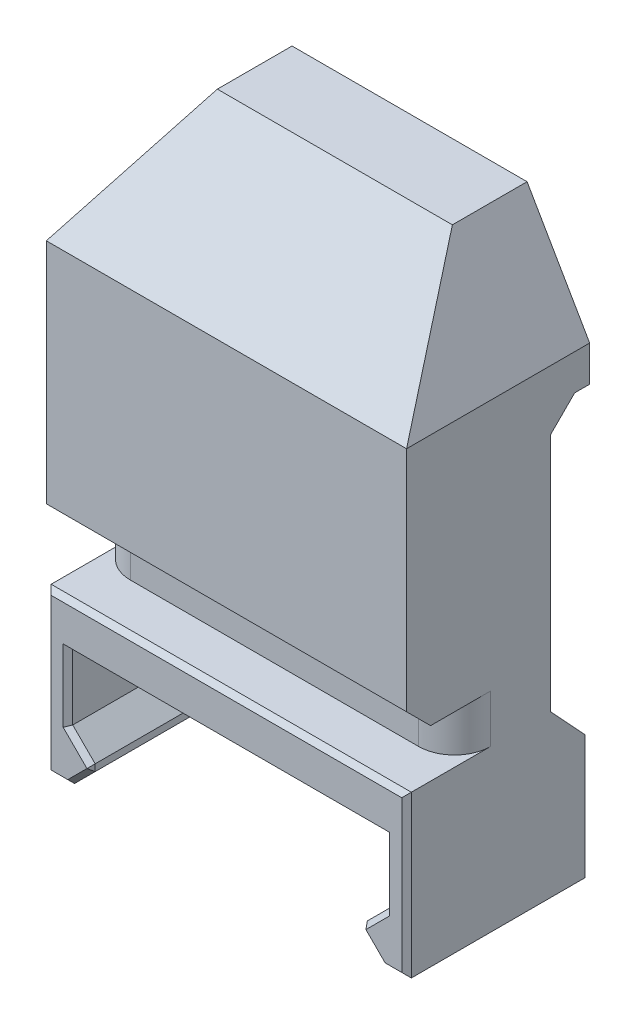
from build123d import *

# Parameters (mm, degrees)
BOSS_EXTRUDE1_DEPTH = 15
FILLET1_R           = 3
CUT_EXTRUDE1_DEPTH  = 16.25
CHAMFER1_SIZE       = 0.4
CUT_EXTRUDE2_DEPTH  = 16.25
CHAMFER2_SIZE       = 2


with BuildPart() as part:
    # Sketch1 → Boss-Extrude1 (new body, symmetric)
    with BuildSketch(Plane(origin=(0, 0, 0), x_dir=(0, 0, -1), z_dir=(1, 0, 0))):
        Polygon((-7.625, 6.7), (-3.625, 6.7), (-3.625, 10.7), (-7.625, 10.7), (-7.625, 31.670562748), (1.404437252, 40.7), (7.625, 40.7), (7.625, 28.7), (6.375, 28.7), (4.375, 26.7), (4.375, 6.7), (7.625, 3.2), (7.625, -6.7), (-7.625, -6.7), align=None)
    extrude(amount=BOSS_EXTRUDE1_DEPTH, both=True)

    # Fillet1
    fillet1_edges = [part.edges().sort_by_distance(p)[0] for p in [
        (-15, 8.7, 3.625),
        (15, 8.7, 3.625),
    ]]
    fillet(fillet1_edges, radius=FILLET1_R)

    # Sketch2 → Cut-Extrude1 (cut, through all)
    with BuildSketch(Plane.XY.offset(7.625)):
        Polygon((-13.2, 2.9), (13.2, 2.9), (13.2, -2.55), (11.05, -4.7), (13.05, -6.7), (-13.05, -6.7), (-11.05, -4.7), (-13.2, -2.55), align=None)
    extrude(amount=-CUT_EXTRUDE1_DEPTH, mode=Mode.SUBTRACT)

    # Chamfer1
    chamfer1_edges = [part.edges().sort_by_distance(p)[0] for p in [
        (15, -1.75, -7.625),
        (-15, -1.75, -7.625),
        (-15, 0, 7.625),
        (0, 6.7, 7.625),
        (14.025, -6.7, -7.625),
        (14.025, -6.7, 7.625),
        (15, 0, 7.625),
        (-14.025, -6.7, -7.625),
        (-14.025, -6.7, 7.625),
        (-13.2, 0.175, -7.625),
        (13.2, 0.175, -7.625),
        (12.125, -3.625, -7.625),
        (12.05, -5.7, -7.625),
        (11.05, -4.7, 0),
        (-12.05, -5.7, -7.625),
        (-12.125, -3.625, -7.625),
        (-11.05, -4.7, 0),
        (-13.2, 0.175, 7.625),
        (-12.125, -3.625, 7.625),
        (-12.05, -5.7, 7.625),
        (12.05, -5.7, 7.625),
        (12.125, -3.625, 7.625),
        (13.2, 0.175, 7.625),
        (0, 2.9, 7.625),
    ]]
    chamfer(chamfer1_edges, length=CHAMFER1_SIZE)

    # Sketch3 → Cut-Extrude2 (cut, through all)
    with BuildSketch(Plane.XY.offset(7.625)):
        Polygon((-15, 31.670562748), (-9.786851972, 40.7), (-15, 40.7), align=None)
        Polygon((15, 31.670562748), (15, 40.7), (9.786851972, 40.7), align=None)
    extrude(amount=-CUT_EXTRUDE2_DEPTH, mode=Mode.SUBTRACT)

    # Chamfer2
    chamfer2_edges = [part.edges().sort_by_distance(p)[0] for p in [
        (0, 10.7, 7.625),
    ]]
    chamfer(chamfer2_edges, length=CHAMFER2_SIZE)


solid = part.part
